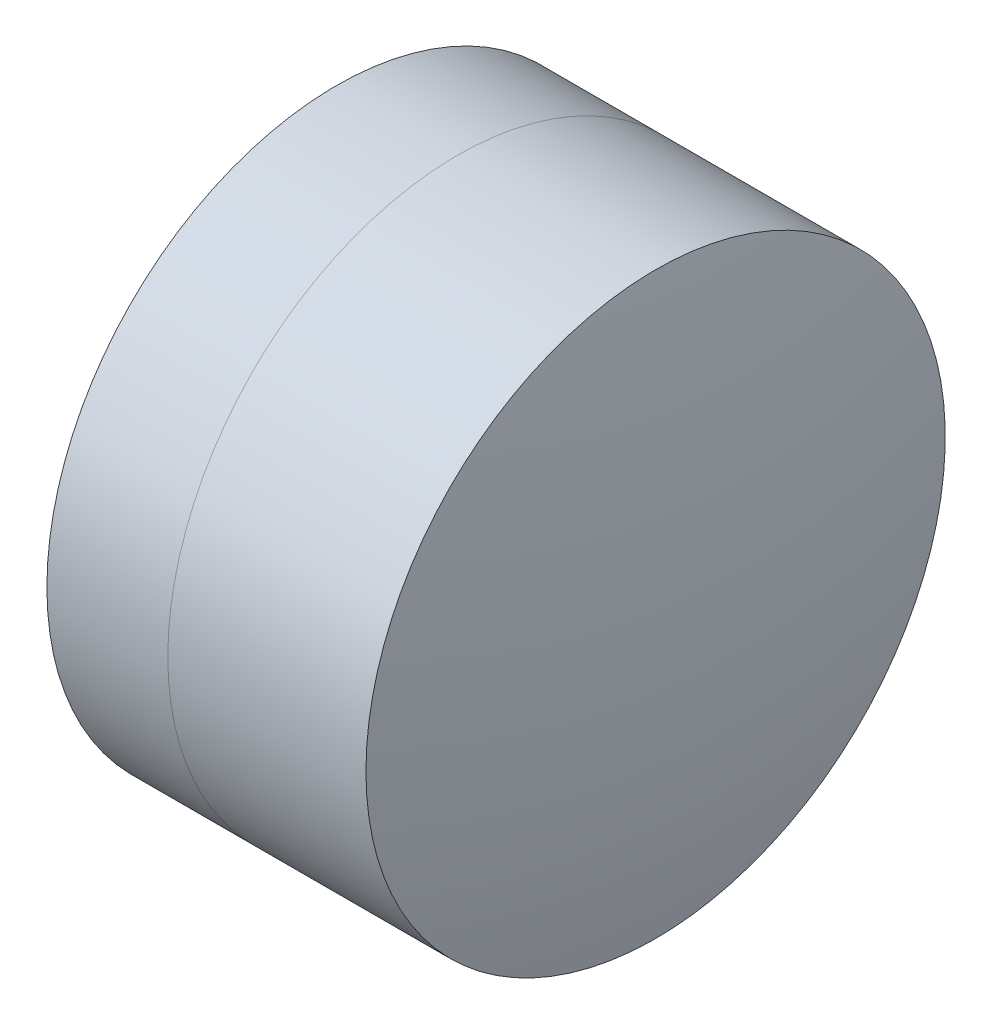
from build123d import *


with BuildPart() as part:
    # 草图1 one side → 旋转1 (revolve)
    with BuildSketch(Plane(origin=(0, 0, 0), x_dir=(1, 0, 0), z_dir=(0, 1, 0)), mode=Mode.PRIVATE) as revolve_1_sk:
        with BuildLine():
            ThreePointArc((4.161104754, 3.15), (3.689777344, 1.606240235), (3.53060434, 0))
            Line((3.53060434, 0), (6.49060434, 0))
            ThreePointArc((6.49060434, 0), (6.23062436, 1.654724858), (5.475736157, 3.15))
            Line((5.475736157, 3.15), (4.161104754, 3.15))
        make_face()
    revolve(revolve_1_sk.sketch.rotate(Axis((-0.816062176, 0, 0), (1, 0, 0)), 180), axis=Axis((-0.816062176, 0, 0), (1, 0, 0)))  # turned: the seam where the file's is


with BuildPart() as body_2:
    # 草图2 one side → 旋转3 (revolve)
    with BuildSketch(Plane(origin=(0, 0, 0), x_dir=(1, 0, 0), z_dir=(0, 1, 0)), mode=Mode.PRIVATE) as revolve_3_sk:
        with BuildLine():
            Line((7.630346895, 3.15), (5.475736157, 3.15))
            ThreePointArc((5.475736157, 3.15), (6.23062436, 1.654724858), (6.49060434, 0))
            Line((6.49060434, 0), (7.97060434, 0))
            ThreePointArc((7.97060434, 0), (7.885293284, 1.584161855), (7.630346895, 3.15))
        make_face()
    revolve(revolve_3_sk.sketch.rotate(Axis((-0.551919993, 0, 0), (1, 0, 0)), 180), axis=Axis((-0.551919993, 0, 0), (1, 0, 0)))  # turned: the seam where the file's is


solid = Compound([part.part, body_2.part])
